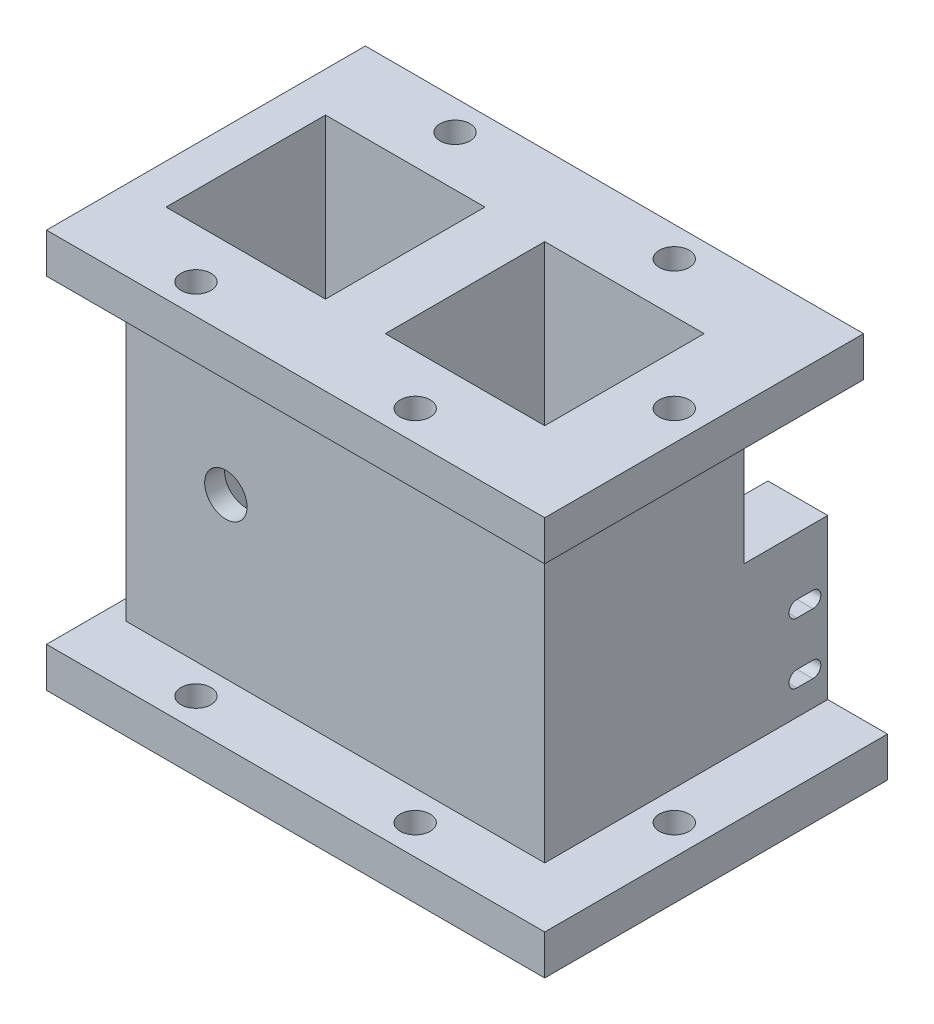
from build123d import *

# Parameters (mm, degrees)
SKETCH2_W               = 79.375
SKETCH2_H               = 50.8
BOSS_EXTRUDE1_DEPTH     = 6.35
SKETCH3_W               = 66.675
SKETCH3_H               = 31.75
SKETCH3_W_2             = 25.4
SKETCH3_H_2             = 25.4
BOSS_EXTRUDE3_DEPTH     = 50.8
CUT_EXTRUDE4_DEPTH      = 75.070102985
CUT_EXTRUDE4_DEPTH_BACK = 75.070102985
SKETCH4_W               = 25.4
SKETCH4_H               = 25.4
SKETCH5_R               = 3.3782
CUT_EXTRUDE5_DEPTH      = 86.50422961
SKETCH6_R               = 2.3876
CUT_EXTRUDE6_DEPTH      = 75.070102985
CIRPATTERN1_COUNT       = 4
SKETCH7_R               = 2.3876
CUT_EXTRUDE7_DEPTH      = 75.070102985
CUT_EXTRUDE8_REACH      = 87.504
SKETCH9_W               = 22.225
SKETCH9_H               = 25.4
SKETCH12_W              = 12.7
SKETCH12_H              = 25.4
BOSS_EXTRUDE5_DEPTH     = 9.525
SKETCH14_W              = 12.7
SKETCH14_H              = 19.812
CUT_EXTRUDE9_DEPTH      = 6.35
SKETCH17_R              = 5.588
CUT_EXTRUDE11_DEPTH     = 6.985
BOSS_EXTRUDE6_DEPTH     = 3.81
CUT_EXTRUDE10_REACH     = 98.597
SCALE1_SCALE            = 1.02


with BuildPart() as part:
    # Sketch2 → Boss-Extrude1 (new body)
    with BuildSketch(Plane(origin=(0, 0, 0), x_dir=(1, 0, 0), z_dir=(0, 1, 0))):
        Rectangle(SKETCH2_W, SKETCH2_H)
    boss_extrude1 = extrude(amount=BOSS_EXTRUDE1_DEPTH)

    # Sketch3 → Boss-Extrude3 (add)
    with BuildSketch(Plane(origin=(0, 6.35, 0), x_dir=(1, 0, 0), z_dir=(0, 1, 0))):
        with Locations((-3.175, 0)):
            Rectangle(SKETCH3_W, SKETCH3_H)
        with Locations((-20.6375, 0)):
            Rectangle(SKETCH3_W_2, SKETCH3_H_2, mode=Mode.SUBTRACT)
        with Locations((14.2875, 0)):
            Rectangle(SKETCH3_W_2, SKETCH3_H_2, mode=Mode.SUBTRACT)
    extrude(amount=BOSS_EXTRUDE3_DEPTH)

    # Mirror1: Boss-Extrude1 across plane
    add(boss_extrude1.mirror(Plane.ZX.offset(31.75)))

    # Sketch4 → Cut-Extrude4 (cut, two sides: drawn at the far end of the back side and taken through both)
    with BuildSketch(Plane(origin=(0, 57.15, 0), x_dir=(1, 0, 0), z_dir=(0, 1, 0)).offset(-CUT_EXTRUDE4_DEPTH_BACK)):
        with Locations((-20.6375, 0)):
            Rectangle(SKETCH4_W, SKETCH4_H)
        with Locations((14.2875, 0)):
            Rectangle(SKETCH4_W, SKETCH4_H)
    extrude(amount=CUT_EXTRUDE4_DEPTH + CUT_EXTRUDE4_DEPTH_BACK, mode=Mode.SUBTRACT)

    # Sketch5 → Cut-Extrude5 (cut, through all)
    with BuildSketch(Plane.XY.offset(15.875)):
        with Locations((-20.6375, 31.75)):
            Circle(SKETCH5_R)
    extrude(amount=-CUT_EXTRUDE5_DEPTH, mode=Mode.SUBTRACT)

    # Sketch6 → Cut-Extrude6 (cut, symmetric)
    with BuildSketch(Plane(origin=(0, 6.35, 0), x_dir=(1, 0, 0), z_dir=(0, 1, 0))):
        with Locations((34.925, 0)):
            Circle(SKETCH6_R)
    cut_extrude6 = extrude(amount=CUT_EXTRUDE6_DEPTH, both=True, mode=Mode.SUBTRACT)

    # CirPattern1: Cut-Extrude6 ×4 about axis, 1 skipped
    cirpattern1_axis = Axis((14.2875, -3.175, 0), (0, 1, 0))
    add([cut_extrude6.rotate(cirpattern1_axis, i * 360 / CIRPATTERN1_COUNT) for i in range(1, CIRPATTERN1_COUNT) if i not in (2,)], mode=Mode.SUBTRACT)

    # Sketch7 → Cut-Extrude7 (cut, symmetric)
    with BuildSketch(Plane(origin=(0, 6.35, 0), x_dir=(1, 0, 0), z_dir=(0, 1, 0))):
        with Locations((-20.6375, -20.6375)):
            Circle(SKETCH7_R)
    cut_extrude7 = extrude(amount=CUT_EXTRUDE7_DEPTH, both=True, mode=Mode.SUBTRACT)

    # Mirror2: Cut-Extrude7 across plane
    add(cut_extrude7.mirror(Plane.XY), mode=Mode.SUBTRACT)

    # Sketch9 → Cut-Extrude8 (cut, up to next)
    with BuildSketch(Plane(origin=(0, 0, -15.875), x_dir=(-1, 0, 0), z_dir=(0, 0, -1)), mode=Mode.PRIVATE) as cut_extrude8_sk1:
        with Locations((-12.7, 19.05)):
            Rectangle(SKETCH9_W, SKETCH9_H)
    cut_extrude8_tool1 = extrude(cut_extrude8_sk1.sketch, amount=-CUT_EXTRUDE8_REACH, mode=Mode.PRIVATE) & part.part
    add(cut_extrude8_tool1.solids().sort_by_distance((12.7, 19.05, -15.875))[0], mode=Mode.SUBTRACT)

    # Sketch12 → Boss-Extrude5 (add)
    with BuildSketch(Plane(origin=(30.1625, 0, 0), x_dir=(0, 0, -1), z_dir=(1, 0, 0))):
        with Locations((19.05, 19.05)):
            Rectangle(SKETCH12_W, SKETCH12_H)
    extrude(amount=-BOSS_EXTRUDE5_DEPTH)

    # Sketch14 → Cut-Extrude9 (cut)
    with BuildSketch(Plane.ZY.offset(-20.6375)):
        with Locations((-19.05, 16.256)):
            Rectangle(SKETCH14_W, SKETCH14_H)
    extrude(amount=-CUT_EXTRUDE9_DEPTH, mode=Mode.SUBTRACT)

    # Sketch17 → Cut-Extrude11 (cut)
    with BuildSketch(Plane.ZY.offset(-26.9875)):
        with Locations((-12.7, 26.123322238)):
            Circle(SKETCH17_R)
    extrude(amount=CUT_EXTRUDE11_DEPTH, mode=Mode.SUBTRACT)

    # Sketch19 → Boss-Extrude6 (add)
    with BuildSketch(Plane(origin=(0, 0, -25.4), x_dir=(-1, 0, 0), z_dir=(0, 0, -1))):
        Polygon((-26.9875, 26.162), (-20.6375, 26.162), (-20.6375, 31.75), (-30.1625, 31.75), (-30.1625, 6.35), (-39.6875, 6.35), (-39.6875, 0), (-20.6375, 0), (-20.6375, 6.35), (-26.9875, 6.35), align=None)
    extrude(amount=BOSS_EXTRUDE6_DEPTH)

    # Sketch15 → Cut-Extrude10 (cut, up to next)
    with BuildSketch(Plane.ZY.offset(-26.9875), mode=Mode.PRIVATE) as cut_extrude10_sk1:
        with BuildLine():
            ThreePointArc((-26.8478, 22.606), (-28.1178, 21.336), (-26.8478, 20.066))
            Line((-26.8478, 20.066), (-24.3078, 20.066))
            ThreePointArc((-24.3078, 20.066), (-23.0378, 21.336), (-24.3078, 22.606))
            Line((-24.3078, 22.606), (-26.8478, 22.606))
        make_face()
    cut_extrude10_tool1 = extrude(cut_extrude10_sk1.sketch, amount=-CUT_EXTRUDE10_REACH, mode=Mode.PRIVATE) & part.part
    # Sketch15 → Cut-Extrude10 (cut, up to next)
    with BuildSketch(Plane.ZY.offset(-26.9875), mode=Mode.PRIVATE) as cut_extrude10_sk2:
        with BuildLine():
            ThreePointArc((-26.8478, 12.954), (-28.1178, 11.684), (-26.8478, 10.414))
            Line((-26.8478, 10.414), (-24.3078, 10.414))
            ThreePointArc((-24.3078, 10.414), (-23.0378, 11.684), (-24.3078, 12.954))
            Line((-24.3078, 12.954), (-26.8478, 12.954))
        make_face()
    cut_extrude10_tool2 = extrude(cut_extrude10_sk2.sketch, amount=-CUT_EXTRUDE10_REACH, mode=Mode.PRIVATE) & part.part
    add(cut_extrude10_tool1.solids().sort_by_distance((26.9875, 21.336, -25.5778))[0], mode=Mode.SUBTRACT)
    add(cut_extrude10_tool2.solids().sort_by_distance((26.9875, 11.684, -25.5778))[0], mode=Mode.SUBTRACT)


with BuildPart() as part_1:
    # Scale1: scaled about (-0.77165693, 31.73889904, -0.207713898)
    add(part.part.scale(SCALE1_SCALE).moved(Location((0.015433139, -0.634777981, 0.004154278))))


solid = part_1.part
